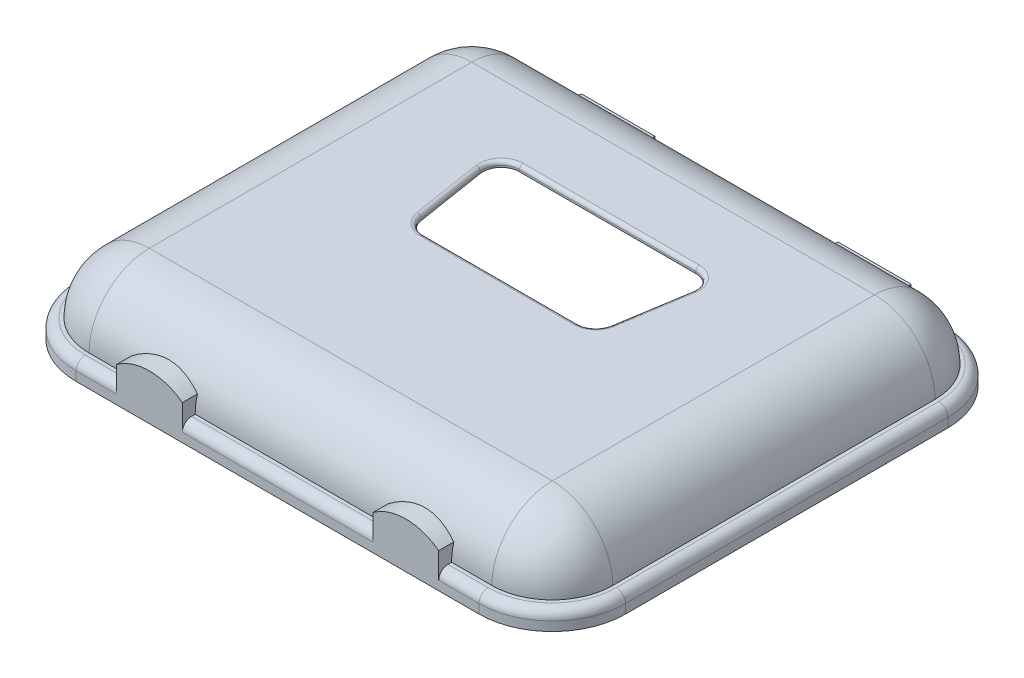
from build123d import *

# Parameters (mm, degrees)
SKETCH1_W           = 286
SKETCH1_H           = 242
BOSS_EXTRUDE1_DEPTH = 43
FILLET1_R           = 33
SHELL1_T            = -3
BOSS_EXTRUDE2_DEPTH = 10
FILLET2_R           = 5
CUT_EXTRUDE2_DEPTH  = 245.651256349
FILLET3_R           = 2
BOSS_EXTRUDE3_REACH = 314.753
SKETCH5_W           = 40
SKETCH5_H           = 18
BOSS_EXTRUDE4_REACH = 314.753


with BuildPart() as part:
    # Sketch1 → Boss-Extrude1 (new body)
    with BuildSketch(Plane(origin=(0, 0, 0), x_dir=(1, 0, 0), z_dir=(0, 1, 0))):
        with Locations((24.44, -38.06)):
            Rectangle(SKETCH1_W, SKETCH1_H)
    extrude(amount=BOSS_EXTRUDE1_DEPTH)

    # Fillet1
    fillet1_edges = [part.edges().sort_by_distance(p)[0] for p in [
        (24.44, 43, 159.06),
        (-118.56, 43, 38.06),
        (24.44, 43, -82.94),
        (-118.56, 21.5, -82.94),
        (-118.56, 21.5, 159.06),
        (167.44, 21.5, 159.06),
        (167.44, 21.5, -82.94),
        (167.44, 43, 38.06),
    ]]
    fillet(fillet1_edges, radius=FILLET1_R)

    # Shell1
    shell1_openings = [part.faces().sort_by_distance(p)[0] for p in [
        (24.44, 0, 38.06),
    ]]
    offset(amount=SHELL1_T, openings=shell1_openings, kind=Kind.INTERSECTION)

    # Sketch2 → Boss-Extrude2 (add)
    with BuildSketch(Plane.XZ):
        with BuildLine():
            Line((-85.56, 166.06), (134.44, 166.06))
            ThreePointArc((134.44, 166.06), (162.724271247, 154.344271247), (174.44, 126.06))
            Line((174.44, 126.06), (174.44, -49.94))
            ThreePointArc((174.44, -49.94), (162.724271247, -78.224271247), (134.44, -89.94))
            Line((134.44, -89.94), (-85.56, -89.94))
            ThreePointArc((-85.56, -89.94), (-113.844271247, -78.224271247), (-125.56, -49.94))
            Line((-125.56, -49.94), (-125.56, 126.06))
            ThreePointArc((-125.56, 126.06), (-113.844271247, 154.344271247), (-85.56, 166.06))
        make_face()
        with BuildLine():
            Line((-85.56, 159.06), (134.44, 159.06))
            ThreePointArc((134.44, 159.06), (157.774523779, 149.394523779), (167.44, 126.06))
            Line((167.44, 126.06), (167.44, -49.94))
            ThreePointArc((167.44, -49.94), (157.774523779, -73.274523779), (134.44, -82.94))
            Line((134.44, -82.94), (-85.56, -82.94))
            ThreePointArc((-85.56, -82.94), (-108.894523779, -73.274523779), (-118.56, -49.94))
            Line((-118.56, -49.94), (-118.56, 126.06))
            ThreePointArc((-118.56, 126.06), (-108.894523779, 149.394523779), (-85.56, 159.06))
        make_face(mode=Mode.SUBTRACT)
    extrude(amount=-BOSS_EXTRUDE2_DEPTH)

    # Fillet2
    fillet2_edges = [part.edges().sort_by_distance(p)[0] for p in [
        (162.724271247, 10, -78.224271247),
        (24.44, 10, -89.94),
        (-113.844271247, 10, -78.224271247),
        (-125.56, 10, 38.06),
        (-113.844271247, 10, 154.344271247),
        (24.44, 10, 166.06),
        (162.724271247, 10, 154.344271247),
        (174.44, 10, 38.06),
    ]]
    fillet(fillet2_edges, radius=FILLET2_R)

    # Sketch4 → Cut-Extrude2 (cut, through all)
    with BuildSketch(Plane(origin=(0, 43, 0), x_dir=(1, 0, 0), z_dir=(0, 1, 0))):
        with BuildLine():
            Line((-23.684825583, 14.14), (72.564825583, 14.14))
            ThreePointArc((72.564825583, 14.14), (80.172419453, 10.630340169), (82.44, 2.564903101))
            Line((82.44, 2.564903101), (76.315174417, -35.835096899))
            ThreePointArc((76.315174417, -35.835096899), (72.930340169, -41.86759387), (66.44, -44.26))
            Line((66.44, -44.26), (-17.56, -44.26))
            ThreePointArc((-17.56, -44.26), (-24.050340169, -41.86759387), (-27.435174417, -35.835096899))
            Line((-27.435174417, -35.835096899), (-33.56, 2.564903101))
            ThreePointArc((-33.56, 2.564903101), (-31.292419453, 10.630340169), (-23.684825583, 14.14))
        make_face()
    extrude(amount=-CUT_EXTRUDE2_DEPTH, mode=Mode.SUBTRACT)

    # Fillet3
    fillet3_edges = [part.edges().sort_by_distance(p)[0] for p in [
        (-24.050340169, 43, 41.86759387),
        (24.44, 43, 44.26),
        (72.930340169, 43, 41.86759387),
        (79.377587208, 43, 16.635096899),
        (80.172419453, 43, -10.630340169),
        (24.44, 43, -14.14),
        (-31.292419453, 43, -10.630340169),
        (-30.497587208, 43, 16.635096899),
    ]]
    fillet(fillet3_edges, radius=FILLET3_R)

    # Sketch5 → Boss-Extrude3 (add, up to next)
    with BuildSketch(Plane(origin=(0, 0, -89.94), x_dir=(-1, 0, 0), z_dir=(0, 0, -1)), mode=Mode.PRIVATE) as boss_extrude3_sk1:
        with Locations((-94.44, 9)):
            Rectangle(SKETCH5_W, SKETCH5_H)
    boss_extrude3_tool1 = extrude(boss_extrude3_sk1.sketch, amount=-BOSS_EXTRUDE3_REACH, mode=Mode.PRIVATE) - part.part
    # Sketch5 → Boss-Extrude3 (add, up to next)
    with BuildSketch(Plane(origin=(0, 0, -89.94), x_dir=(-1, 0, 0), z_dir=(0, 0, -1)), mode=Mode.PRIVATE) as boss_extrude3_sk2:
        with Locations((45.56, 9)):
            Rectangle(SKETCH5_W, SKETCH5_H)
    boss_extrude3_tool2 = extrude(boss_extrude3_sk2.sketch, amount=-BOSS_EXTRUDE3_REACH, mode=Mode.PRIVATE) - part.part
    add(boss_extrude3_tool1.solids().sort_by_distance((94.44, 9, -89.94))[0])
    add(boss_extrude3_tool2.solids().sort_by_distance((-45.56, 9, -89.94))[0])

    # Sketch6 → Boss-Extrude4 (add, up to next)
    with BuildSketch(Plane.XY.offset(166.06), mode=Mode.PRIVATE) as boss_extrude4_sk1:
        with BuildLine():
            Line((-63.56, 5), (-27.56, 5))
            Line((-27.56, 5), (-27.56, 19))
            ThreePointArc((-27.56, 19), (-45.56, 25), (-63.56, 19))
            Line((-63.56, 19), (-63.56, 5))
        make_face()
    boss_extrude4_tool1 = extrude(boss_extrude4_sk1.sketch, amount=-BOSS_EXTRUDE4_REACH, mode=Mode.PRIVATE) - part.part
    # Sketch6 → Boss-Extrude4 (add, up to next)
    with BuildSketch(Plane.XY.offset(166.06), mode=Mode.PRIVATE) as boss_extrude4_sk2:
        with BuildLine():
            ThreePointArc((112.44, 19), (94.44, 25), (76.44, 19))
            Line((76.44, 19), (76.44, 5))
            Line((76.44, 5), (112.44, 5))
            Line((112.44, 5), (112.44, 19))
        make_face()
    boss_extrude4_tool2 = extrude(boss_extrude4_sk2.sketch, amount=-BOSS_EXTRUDE4_REACH, mode=Mode.PRIVATE) - part.part
    add(boss_extrude4_tool1.solids().sort_by_distance((-45.56, 14.129204, 166.06))[0])
    add(boss_extrude4_tool2.solids().sort_by_distance((94.44, 14.129204, 166.06))[0])


solid = part.part
